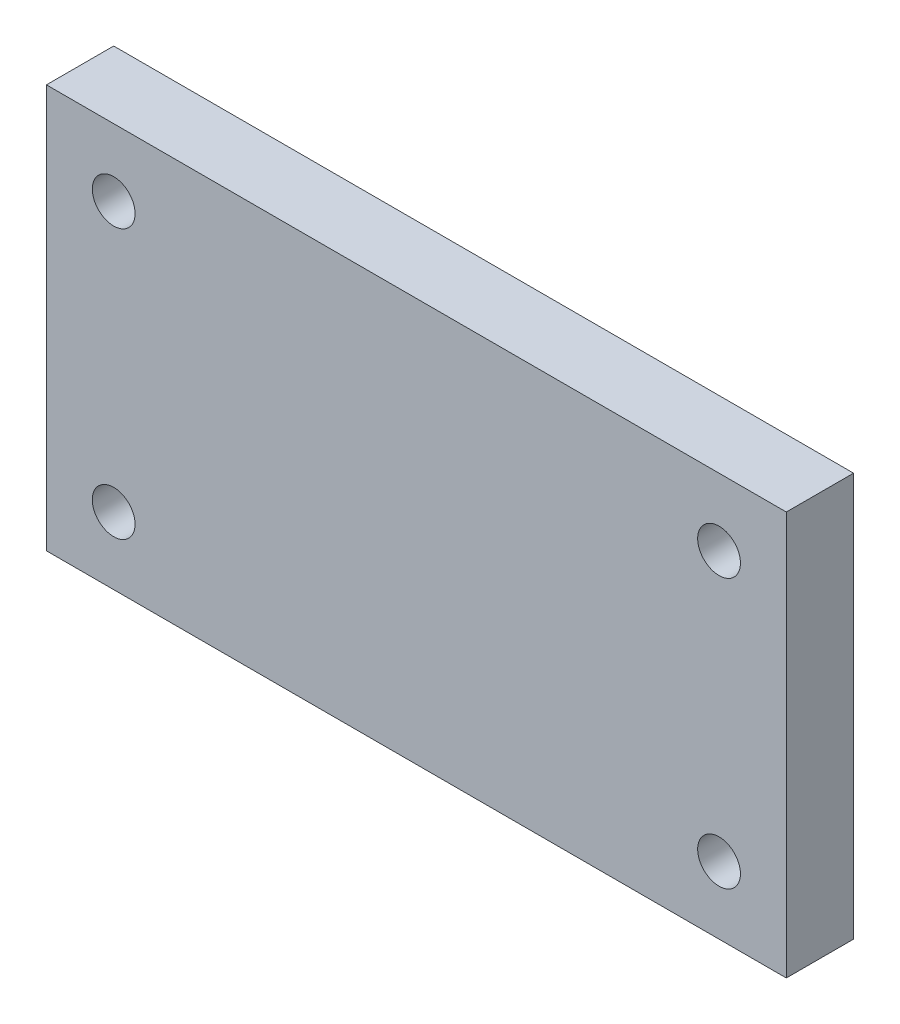
from build123d import *

# Parameters (mm, degrees)
SKETCH1_W           = 69.85
SKETCH1_H           = 38.1
SKETCH1_R           = 2.0193
BOSS_EXTRUDE1_DEPTH = 6.35


with BuildPart() as part:
    # Sketch1 → Boss-Extrude1 (new body)
    with BuildSketch(Plane.XY):
        with Locations((57.9752, 0)):
            Rectangle(SKETCH1_W, SKETCH1_H)
        with Locations((29.4002, -12.7)):
            Circle(SKETCH1_R, mode=Mode.SUBTRACT)
        with Locations((86.5502, -12.7)):
            Circle(SKETCH1_R, mode=Mode.SUBTRACT)
        with Locations((29.4002, 12.7)):
            Circle(SKETCH1_R, mode=Mode.SUBTRACT)
        with Locations((86.5502, 12.7)):
            Circle(SKETCH1_R, mode=Mode.SUBTRACT)
    extrude(amount=BOSS_EXTRUDE1_DEPTH)


solid = part.part
